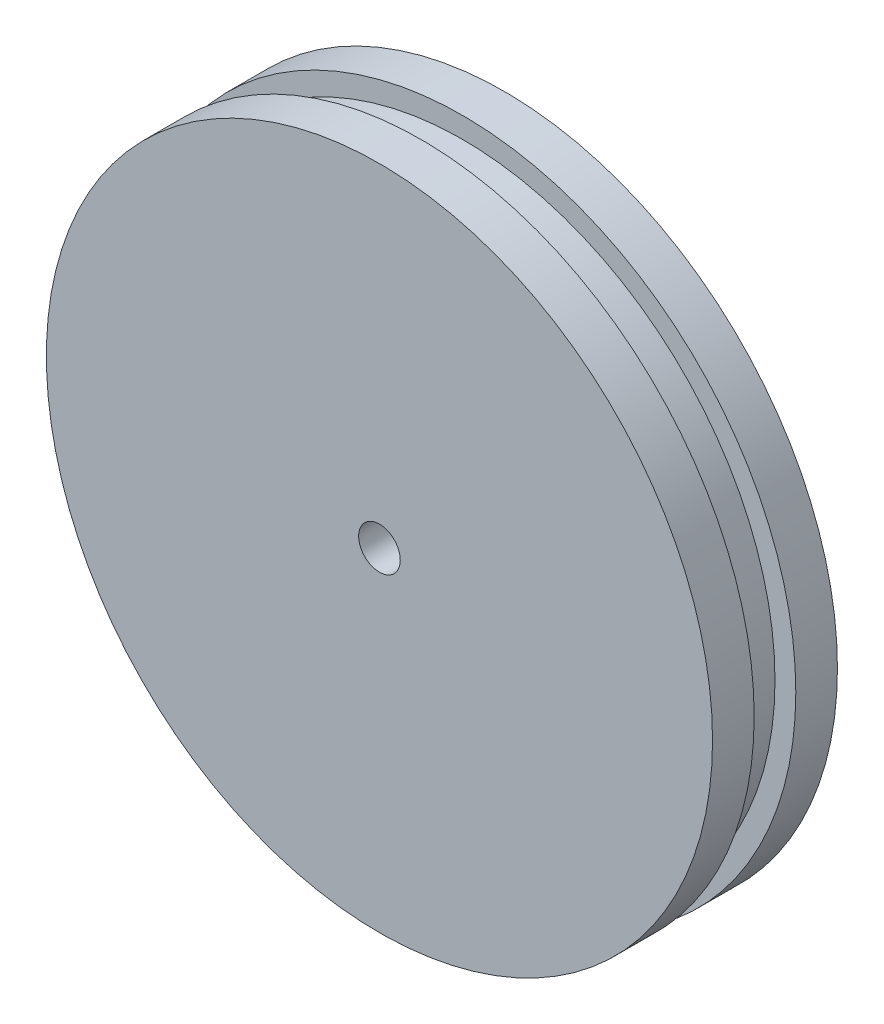
from build123d import *

# Parameters (mm, degrees)
CROQUIS2_R              = 56
SALIENTE_EXTRUIR1_DEPTH = 7
CROQUIS3_R              = 52.5
SALIENTE_EXTRUIR2_DEPTH = 7
CROQUIS4_R              = 56
SALIENTE_EXTRUIR3_DEPTH = 7
CROQUIS5_R              = 3.5
CORTAR_EXTRUIR1_DEPTH   = 77


with BuildPart() as part:
    # Croquis2 → Saliente-Extruir1 (new body)
    with BuildSketch(Plane.XY):
        Circle(CROQUIS2_R)
    extrude(amount=SALIENTE_EXTRUIR1_DEPTH)

    # Croquis3 → Saliente-Extruir2 (add)
    with BuildSketch(Plane.XY.offset(7)):
        Circle(CROQUIS3_R)
    extrude(amount=SALIENTE_EXTRUIR2_DEPTH)

    # Croquis4 → Saliente-Extruir3 (add)
    with BuildSketch(Plane.XY.offset(14)):
        Circle(CROQUIS4_R)
    extrude(amount=SALIENTE_EXTRUIR3_DEPTH)

    # Croquis5 → Cortar-Extruir1 (cut)
    with BuildSketch(Plane.XY.offset(21)):
        Circle(CROQUIS5_R)
    extrude(amount=-CORTAR_EXTRUIR1_DEPTH, mode=Mode.SUBTRACT)


solid = part.part
